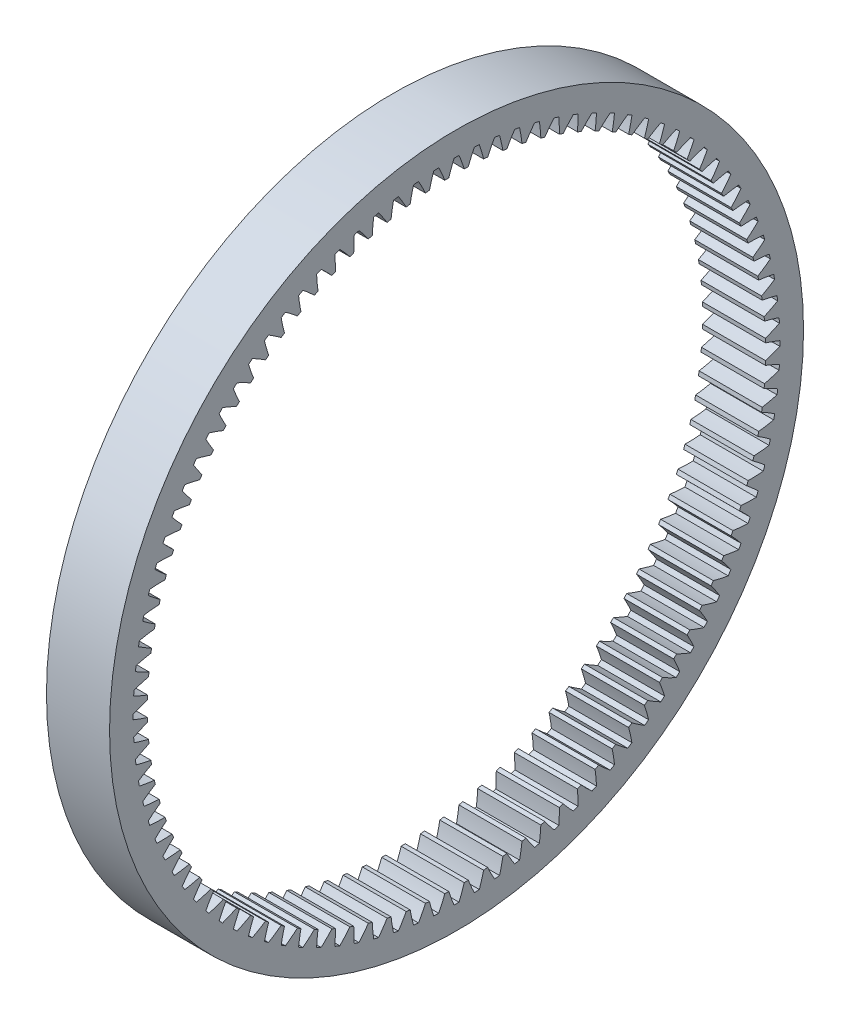
from build123d import *

# Parameters (mm, degrees)
BASPROSKE_W     = 5
BASPROSKE_H     = 3
TOOTHCUT_DEPTH  = 40.210967853
TEETHCUTS_COUNT = 100
TEETHCUTS_ANGLE = 356.4


with BuildPart() as part:
    # BasProSke → Base-Revolve (revolve)
    with BuildSketch(Plane(origin=(0, 0, 0), x_dir=(1, 0, 0), z_dir=(0, 1, 0)), mode=Mode.PRIVATE) as base_revolve_sk:
        with Locations((2.5, 26)):
            Rectangle(BASPROSKE_W, BASPROSKE_H)
    revolve(base_revolve_sk.sketch.rotate(Axis((-10, 0, 0), (1, 0, 0)), 180), axis=Axis((-10, 0, 0), (1, 0, 0)))

    # TooCutSke → ToothCut (cut, through all)
    with BuildSketch(Plane(origin=(0, 0, 0), x_dir=(0, 0, -1), z_dir=(1, 0, 0))):
        with BuildLine():
            ThreePointArc((0.615727945, 24.466853583), (0.420389829, 25.051217904), (0.196493364, 25.625246659))
            ThreePointArc((0.196493364, 25.625246659), (0, 25.626), (-0.196493364, 25.625246659))
            ThreePointArc((-0.196493364, 25.625246659), (-0.420389829, 25.051217904), (-0.615727945, 24.466853583))
            ThreePointArc((-0.615727945, 24.466853583), (0, 24.4746), (0.615727945, 24.466853583))
        make_face()
    toothcut = extrude(amount=TOOTHCUT_DEPTH, mode=Mode.SUBTRACT)

    # TeethCuts: ToothCut ×100 about axis
    teethcuts_axis = Axis((-10, 0, 0), (1, 0, 0))
    for i in range(1, TEETHCUTS_COUNT):
        add(toothcut.rotate(teethcuts_axis, i * TEETHCUTS_ANGLE / (TEETHCUTS_COUNT - 1)), mode=Mode.SUBTRACT)


solid = part.part
